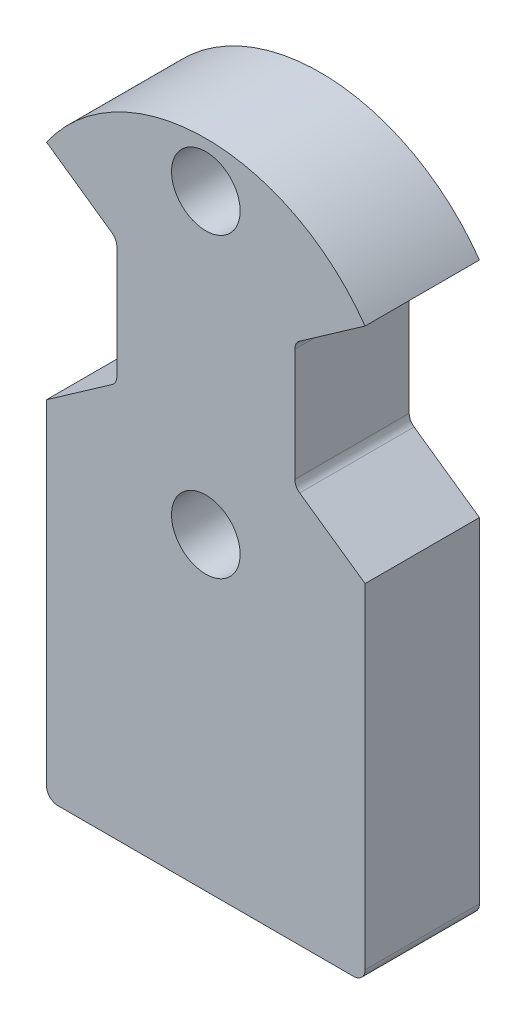
from build123d import *

# Parameters (mm, degrees)
SKETCH_1_R          = 8.5
EXTRUDE_1_DEPTH     = 5
SKETCH_2_R          = 1.5
CUT_EXTRUDE_1_DEPTH = 5
CUT_EXTRUDE_2_DEPTH = 6
EXTRUDE_2_DEPTH     = 5
FILLET_2_R          = 0.5
CUT_EXTRUDE_3_DEPTH = 10
FILLET_3_R          = 0.5


with BuildPart() as part:
    # 草图1 → 凸台-拉伸1 (new body)
    with BuildSketch(Plane.XY):
        Circle(SKETCH_1_R)
    extrude(amount=EXTRUDE_1_DEPTH)

    # 草图2 → 切除-拉伸1 (cut)
    with BuildSketch(Plane.XY.offset(5)):
        with Locations((0, 6.5)):
            Circle(SKETCH_2_R)
        with Locations((0, -6.5)):
            Circle(SKETCH_2_R)
    extrude(amount=-CUT_EXTRUDE_1_DEPTH, mode=Mode.SUBTRACT)

    # 草图3 → 切除-拉伸2 (cut, through all)
    with BuildSketch(Plane(origin=(0, 0, 0), x_dir=(-1, 0, 0), z_dir=(0, 0, -1))):
        with BuildLine():
            Line((6.962792376, 4.875399709), (3.89097221, 2.724488073))
            ThreePointArc((3.89097221, 2.724488073), (4.530155516, 1.428352548), (4.75, 0))
            ThreePointArc((4.75, 0), (4.530155516, -1.428352548), (3.89097221, -2.724488073))
            Line((3.89097221, -2.724488073), (6.962792376, -4.875399709))
            ThreePointArc((6.962792376, -4.875399709), (8.106594081, -2.555999296), (8.5, 0))
            ThreePointArc((8.5, 0), (8.106594081, 2.555999296), (6.962792376, 4.875399709))
        make_face()
    cut_extrude_2 = extrude(amount=-CUT_EXTRUDE_2_DEPTH, mode=Mode.SUBTRACT)

    # 镜向1: 切除-拉伸2 across plane
    add(cut_extrude_2.mirror(Plane(origin=(0, 0, 0), x_dir=(0, 0, 1), z_dir=(1, 0, 0))), mode=Mode.SUBTRACT)


with BuildPart() as body_2:
    # 草图4 → 凸台-拉伸2 (new body)
    with BuildSketch(Plane(origin=(0, 0, 0), x_dir=(-1, 0, 0), z_dir=(0, 0, -1))):
        with BuildLine():
            ThreePointArc((6.962792376, -4.875399709), (0, -8.5), (-6.962792376, -4.875399709))
            Line((-6.962792376, -4.875399709), (-6.962792376, -20))
            Line((-6.962792376, -20), (6.962792376, -20))
            Line((6.962792376, -20), (6.962792376, -4.875399709))
        make_face()
    extrude(amount=-EXTRUDE_2_DEPTH)


with BuildPart() as part_1:
    add(part.part)

    # Combine 1: union body 2
    add(body_2.part)

    # 圆角2
    fillet_2_edges = [part_1.edges().sort_by_distance(p)[0] for p in [
        (-6.962792376, -20, 2.5),
        (6.962792376, -20, 2.5),
    ]]
    fillet(fillet_2_edges, radius=FILLET_2_R)

    # 草图6 → 切除-拉伸3 (cut)
    with BuildSketch(Plane(origin=(0, 0, 0), x_dir=(-1, 0, 0), z_dir=(0, 0, -1))):
        with BuildLine():
            Line((3.89097221, 2.724488073), (3.89097221, -2.724488073))
            ThreePointArc((3.89097221, -2.724488073), (4.75, 0), (3.89097221, 2.724488073))
        make_face()
        with BuildLine():
            Line((-3.89097221, 2.724488073), (-3.89097221, -2.724488073))
            ThreePointArc((-3.89097221, -2.724488073), (-4.75, 0), (-3.89097221, 2.724488073))
        make_face()
    extrude(amount=-CUT_EXTRUDE_3_DEPTH, mode=Mode.SUBTRACT)

    # 圆角3
    fillet_3_edges = [part_1.edges().sort_by_distance(p)[0] for p in [
        (-3.89097221, -2.724488073, 2.5),
        (-3.89097221, 2.724488073, 2.5),
        (3.89097221, 2.724488073, 2.5),
        (3.89097221, -2.724488073, 2.5),
    ]]
    fillet(fillet_3_edges, radius=FILLET_3_R)


solid = part_1.part
